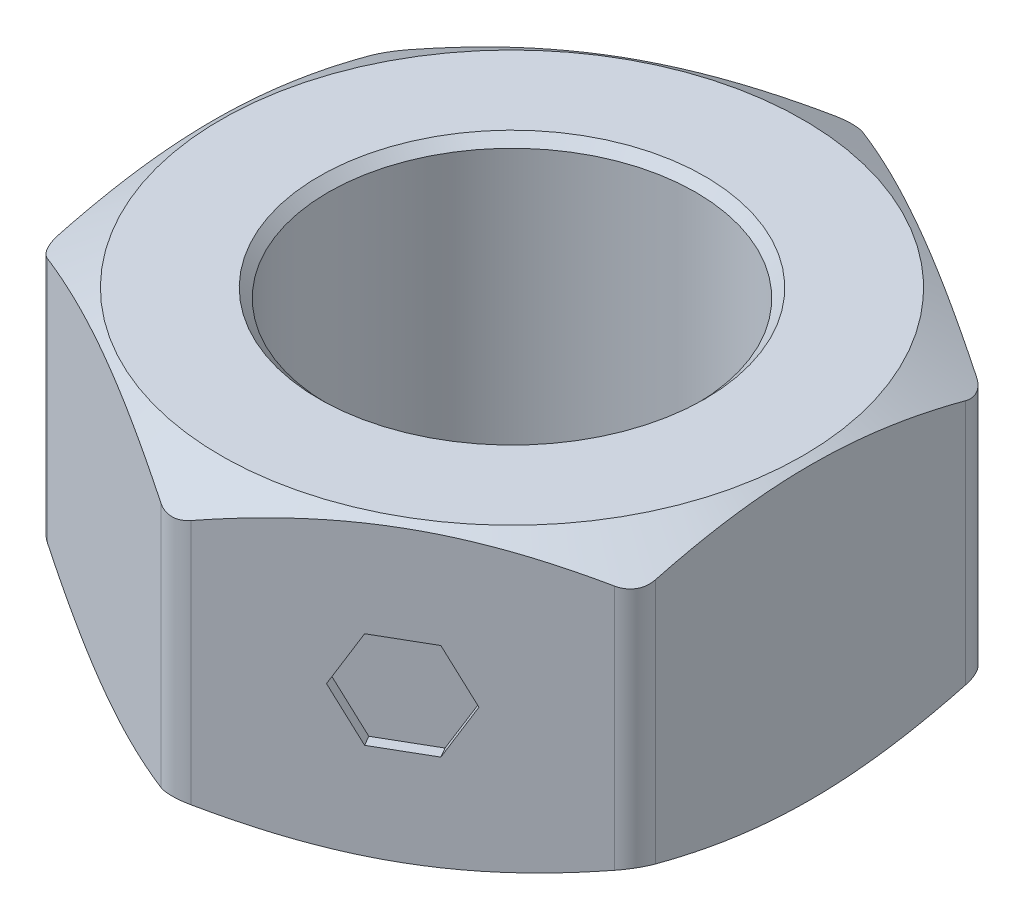
from build123d import *

# Parameters (mm, degrees)
SKETCH2_R                = 4
BOSS_EXTRUDE1_DEPTH      = 3.25
BOSS_EXTRUDE1_DEPTH_BACK = 3.25
FILLET1_R                = 0.65
CUT_EXTRUDE2_DEPTH       = 0.25


with BuildPart() as part:
    # Sketch2 → Boss-Extrude1 (new body, two sides)
    with BuildSketch(Plane(origin=(0, 0, 0), x_dir=(1, 0, 0), z_dir=(0, 1, 0))) as boss_extrude1_sk:
        Polygon((0, 7.505553499), (-6.5, 3.75277675), (-6.5, -3.75277675), (0, -7.505553499), (6.5, -3.75277675), (6.5, 3.75277675), align=None)
        Circle(SKETCH2_R, mode=Mode.SUBTRACT)
    extrude(amount=BOSS_EXTRUDE1_DEPTH)
    extrude(boss_extrude1_sk.sketch, amount=-BOSS_EXTRUDE1_DEPTH_BACK)

    # Fillet1
    fillet1_edges = [part.edges().sort_by_distance(p)[0] for p in [
        (6.5, 0, -3.75277675),
        (6.5, 0, 3.75277675),
        (0, 0, 7.505553499),
        (-6.5, 0, 3.75277675),
        (-6.5, 0, -3.75277675),
        (0, 0, -7.505553499),
    ]]
    fillet(fillet1_edges, radius=FILLET1_R)

    # Sketch3 → Cut-Revolve2 (revolve, cut)
    with BuildSketch(Plane(origin=(0, 0, 0), x_dir=(0, 0, -1), z_dir=(1, 0, 0))):
        Polygon((6.3375, -3.25), (7.505553499, -2.575623998), (7.505553499, -3.25), align=None)
        Polygon((4, 3.25), (4, 3.05), (4.2, 3.25), align=None)
        Polygon((4, -3.25), (4, -3.05), (4.2, -3.25), align=None)
        Polygon((6.3375, 3.25), (7.505553499, 2.575623998), (7.505553499, 3.25), align=None)
    revolve(axis=Axis((0, -3.25, 0), (0, 1, 0)), mode=Mode.SUBTRACT)

    # Sketch12 → Cut-Extrude2 (cut)
    with BuildSketch(Plane(origin=(3.25, 0, 5.629165125), x_dir=(0.866025404, 0, -0.5), z_dir=(0.5, 0, 0.866025404))):
        Polygon((-1.214814445, 0), (-0.607407223, -1.05206017), (0.607407223, -1.05206017), (1.214814445, 0), (0.607407223, 1.05206017), (-0.607407223, 1.05206017), align=None)
    extrude(amount=-CUT_EXTRUDE2_DEPTH, mode=Mode.SUBTRACT)


solid = part.part
